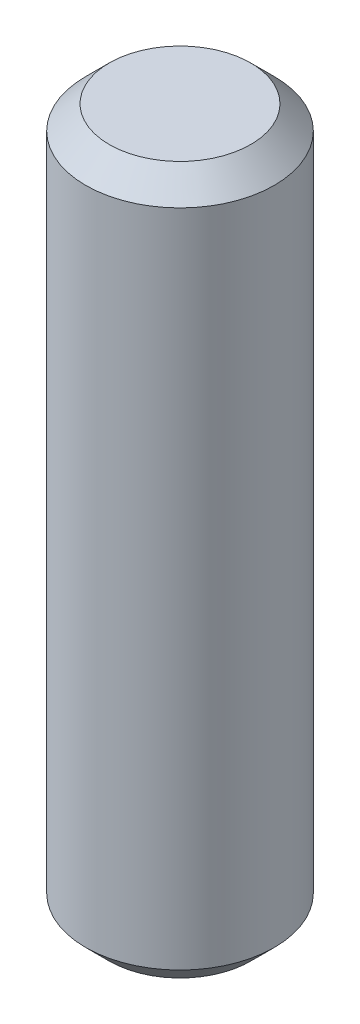
from build123d import *

# Parameters (mm, degrees)
SKETCH1_R           = 4
BOSS_EXTRUDE1_DEPTH = 15
CHAMFER1_SIZE       = 1


with BuildPart() as part:
    # Sketch1 → Boss-Extrude1 (new body, symmetric)
    with BuildSketch(Plane(origin=(0, 0, 0), x_dir=(1, 0, 0), z_dir=(0, 1, 0))):
        Circle(SKETCH1_R)
    extrude(amount=BOSS_EXTRUDE1_DEPTH, both=True)

    # Chamfer1
    chamfer1_edges = [part.edges().sort_by_distance(p)[0] for p in [
        (-4, -15, 0),
        (-4, 15, 0),
    ]]
    chamfer(chamfer1_edges, length=CHAMFER1_SIZE)


solid = part.part
